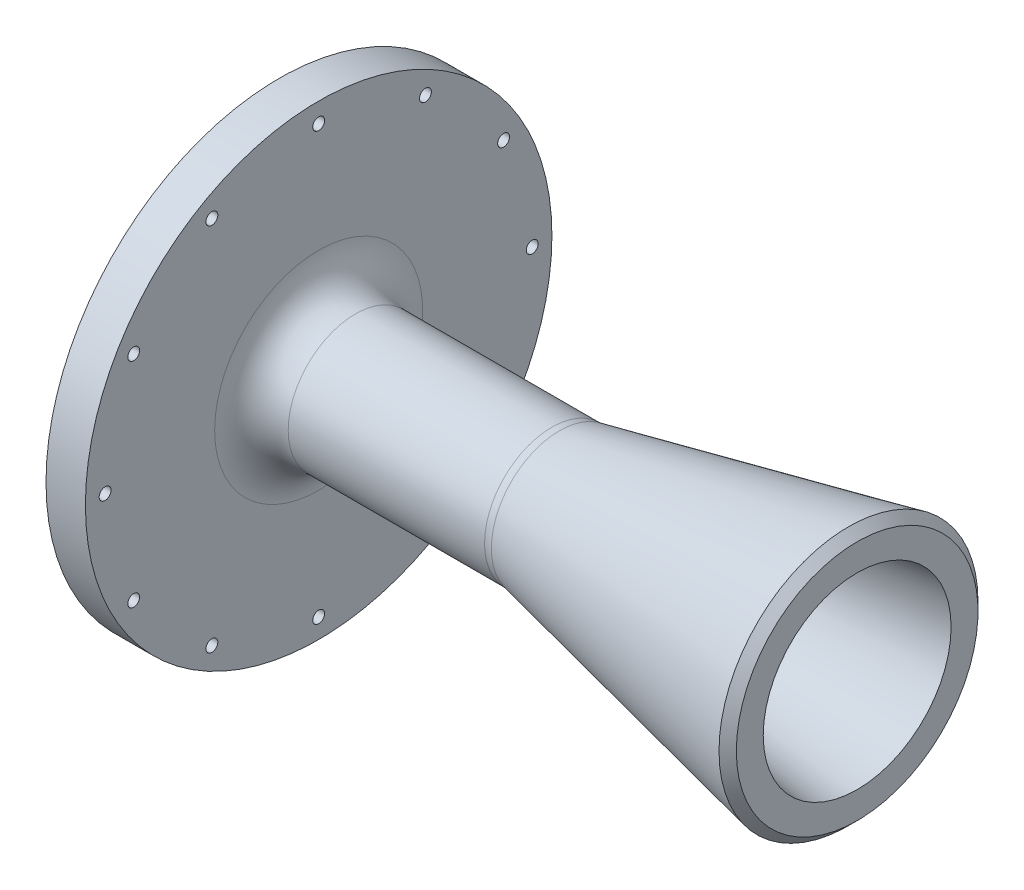
from build123d import *

# Parameters (mm, degrees)
FLANGE_HOLES_D     = 2.8702
FLANGE_HOLES_DEPTH = 9.525
DOWEL_HOLES_D      = 4.7625
DOWEL_HOLES_DEPTH  = 6.35
DOWEL_HOLES_TIP    = 1.430799349
FILLET1_R          = 8.89
CHAMFER1_SIZE2     = 2.54
CHAMFER1_SIZE      = 2.141545552


with BuildPart() as part:
    # Sketch2 → Main Structure (revolve)
    with BuildSketch(Plane.XY):
        Polygon((0, 20.583496156), (0, 56.388), (9.525, 56.388), (9.525, 16.256), (66.806461084, 16.256), (139.7, 31.75), (139.7, 22.7076), (60.325, 12.720781818), (60.325, 14.351), (10.795, 14.351), align=None)
    revolve(axis=Axis((0, 0, 0), (1, 0, 0)))

    # Flange Holes
    with Locations(Plane.ZY):
        with Locations((0, -51.6255), (-25.81275, -44.708994483), (-44.708994483, -25.81275), (-51.6255, 0), (-44.708994483, 25.81275), (-25.81275, 44.708994483), (0, 51.6255), (25.81275, 44.708994483), (44.708994483, 25.81275), (51.6255, 0), (44.708994483, -25.81275), (25.81275, -44.708994483)):
            Hole(FLANGE_HOLES_D / 2, depth=FLANGE_HOLES_DEPTH)

    # Dowel Holes
    with Locations(Plane.ZY):
        with Locations((49.866403745, -13.361662613), (-49.866403745, 13.361662613)):
            Hole(DOWEL_HOLES_D / 2, depth=DOWEL_HOLES_DEPTH)
            with Locations((0, 0, -(DOWEL_HOLES_DEPTH + DOWEL_HOLES_TIP / 2))):  # 118° drill point
                Cone(0, DOWEL_HOLES_D / 2, DOWEL_HOLES_TIP, mode=Mode.SUBTRACT)

    # Fillet1
    fillet1_edges = [part.edges().sort_by_distance(p)[0] for p in [
        (66.806461084, -16.256, 0),
        (9.525, -16.256, 0),
    ]]
    fillet(fillet1_edges, radius=FILLET1_R)

    # Sketch13 → Cut-Revolve1 (revolve, cut)
    with BuildSketch(Plane(origin=(0, 0, 0), x_dir=(1, 0, 0), z_dir=(0, 1, 0))):
        Polygon((0, 38.1), (3.33331808, 0), (0, 0), align=None)
    revolve(axis=Axis((3.33331808, 0, 0), (-1, 0, 0)), mode=Mode.SUBTRACT)

    # Chamfer1
    chamfer1_edges = [part.edges().sort_by_distance(p)[0] for p in [
        (139.7, -31.75, 0),
    ]]
    chamfer(chamfer1_edges, length=CHAMFER1_SIZE, length2=CHAMFER1_SIZE2)


solid = part.part
